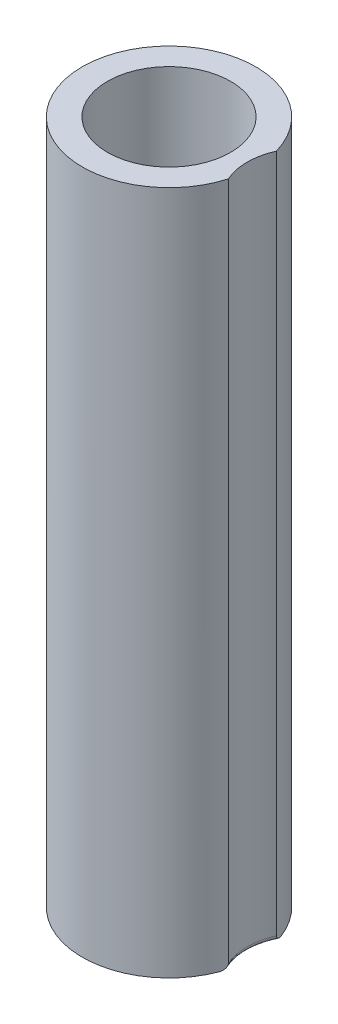
from build123d import *

# Parameters (mm, degrees)
SKETCH1_R           = 6.3
BOSS_EXTRUDE1_DEPTH = 70
FILLET1_R           = 0.5


with BuildPart() as part:
    # Sketch1 → Boss-Extrude1 (new body)
    with BuildSketch(Plane(origin=(0, 0, 0), x_dir=(1, 0, 0), z_dir=(0, 1, 0))):
        with BuildLine():
            ThreePointArc((8.52734375, 2.459681599), (-8.875, 0), (8.52734375, -2.459681599))
            ThreePointArc((8.52734375, -2.459681599), (8, 0), (8.52734375, 2.459681599))
        make_face()
        with Locations(Location((0, 0, 0), (0, 0, 270))):  # turned: the seam where the file's is
            Circle(SKETCH1_R, mode=Mode.SUBTRACT)
    extrude(amount=BOSS_EXTRUDE1_DEPTH)

    # Fillet1
    fillet1_edges = [part.edges().sort_by_distance(p)[0] for p in [
        (8, 0, 0),
    ]]
    fillet(fillet1_edges, radius=FILLET1_R)


solid = part.part
